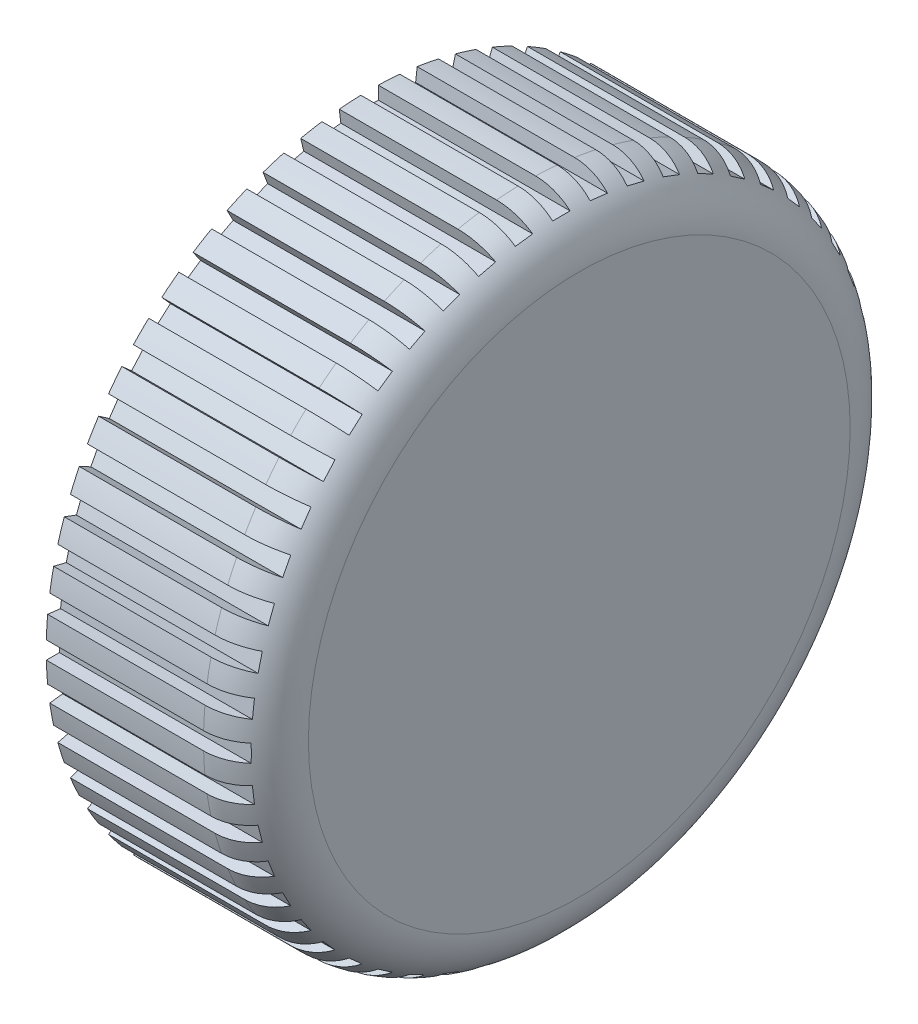
from build123d import *

# Parameters (mm, degrees)
SKETCH_2_W          = 2
SKETCH_2_H          = 3
SKETCH_2_W_2        = 3
SKETCH_2_H_2        = 2
CUT_EXTRUDE_2_DEPTH = 25


with BuildPart() as part:
    # Эскиз1 → Повернуть1 (revolve)
    with BuildSketch(Plane.XY):
        with BuildLine():
            Line((0, 37), (0, 30.3))
            Line((0, 30.3), (16, 30.3))
            Line((16, 30.3), (16, 0))
            Line((16, 0), (24, 0))
            Line((24, 0), (24, 31))
            ThreePointArc((24, 31), (22.242640687, 35.242640687), (18, 37))
            Line((18, 37), (0, 37))
        make_face()
    revolve(axis=Axis((0, 0, 0), (1, 0, 0)))

    # Эскиз2 → Вырез-Вытянуть2 (cut, through all)
    with BuildSketch(Plane.ZY):
        with Locations((0, 37)):
            Rectangle(SKETCH_2_W, SKETCH_2_H)
        Polygon((5.633371064, 38.098754973), (5.271761023, 35.12062835), (3.286343275, 35.361701711), (3.647953316, 38.339828333), align=None)
        Polygon((10.184594892, 37.141944307), (9.4666479, 34.229118854), (7.524764265, 34.707750183), (8.242711258, 37.620575635), align=None)
        Polygon((14.587304394, 35.643520456), (13.523489733, 32.838471728), (11.653457247, 33.547681502), (12.717271908, 36.35273023), align=None)
        Polygon((18.777298149, 33.625333816), (17.383128633, 30.968965739), (15.612216582, 31.898412083), (17.006386098, 34.55478016), align=None)
        Polygon((22.693476615, 31.11681409), (20.989282375, 28.647862492), (19.343314643, 29.783991986), (21.047508883, 32.252943584), align=None)
        Polygon((26.27873309, 28.154541146), (24.289365116, 25.909008902), (22.792343619, 27.235254218), (24.781711594, 29.480786463), align=None)
        Polygon((29.480786463, 24.781711594), (27.235254218, 22.792343619), (25.909008902, 24.289365116), (28.154541146, 26.27873309), align=None)
        Polygon((32.252943584, 21.047508883), (29.783991986, 19.343314643), (28.647862492, 20.989282375), (31.11681409, 22.693476615), align=None)
        Polygon((34.55478016, 17.006386098), (31.898412083, 15.612216582), (30.968965739, 17.383128633), (33.625333816, 18.777298149), align=None)
        Polygon((36.35273023, 12.717271908), (33.547681502, 11.653457247), (32.838471728, 13.523489733), (35.643520456, 14.587304394), align=None)
        Polygon((37.620575635, 8.242711258), (34.707750183, 7.524764265), (34.229118854, 9.4666479), (37.141944307, 10.184594892), align=None)
        Polygon((38.339828333, 3.647953316), (35.361701711, 3.286343275), (35.12062835, 5.271761023), (38.098754973, 5.633371064), align=None)
        with Locations((37, 0)):
            Rectangle(SKETCH_2_W_2, SKETCH_2_H_2)
        Polygon((38.098754973, -5.633371064), (35.12062835, -5.271761023), (35.361701711, -3.286343275), (38.339828333, -3.647953316), align=None)
        Polygon((37.141944307, -10.184594892), (34.229118854, -9.4666479), (34.707750183, -7.524764265), (37.620575635, -8.242711258), align=None)
        Polygon((35.643520456, -14.587304394), (32.838471728, -13.523489733), (33.547681502, -11.653457247), (36.35273023, -12.717271908), align=None)
        Polygon((33.625333816, -18.777298149), (30.968965739, -17.383128633), (31.898412083, -15.612216582), (34.55478016, -17.006386098), align=None)
        Polygon((31.11681409, -22.693476615), (28.647862492, -20.989282375), (29.783991986, -19.343314643), (32.252943584, -21.047508883), align=None)
        Polygon((28.154541146, -26.27873309), (25.909008902, -24.289365116), (27.235254218, -22.792343619), (29.480786463, -24.781711594), align=None)
        Polygon((24.781711594, -29.480786463), (22.792343619, -27.235254218), (24.289365116, -25.909008902), (26.27873309, -28.154541146), align=None)
        Polygon((21.047508883, -32.252943584), (19.343314643, -29.783991986), (20.989282375, -28.647862492), (22.693476615, -31.11681409), align=None)
        Polygon((17.006386098, -34.55478016), (15.612216582, -31.898412083), (17.383128633, -30.968965739), (18.777298149, -33.625333816), align=None)
        Polygon((12.717271908, -36.35273023), (11.653457247, -33.547681502), (13.523489733, -32.838471728), (14.587304394, -35.643520456), align=None)
        Polygon((8.242711258, -37.620575635), (7.524764265, -34.707750183), (9.4666479, -34.229118854), (10.184594892, -37.141944307), align=None)
        Polygon((3.647953316, -38.339828333), (3.286343275, -35.361701711), (5.271761023, -35.12062835), (5.633371064, -38.098754973), align=None)
        with Locations((0, -37)):
            Rectangle(SKETCH_2_W, SKETCH_2_H)
        Polygon((-5.633371064, -38.098754973), (-5.271761023, -35.12062835), (-3.286343275, -35.361701711), (-3.647953316, -38.339828333), align=None)
        Polygon((-10.184594892, -37.141944307), (-9.4666479, -34.229118854), (-7.524764265, -34.707750183), (-8.242711258, -37.620575635), align=None)
        Polygon((-14.587304394, -35.643520456), (-13.523489733, -32.838471728), (-11.653457247, -33.547681502), (-12.717271908, -36.35273023), align=None)
        Polygon((-18.777298149, -33.625333816), (-17.383128633, -30.968965739), (-15.612216582, -31.898412083), (-17.006386098, -34.55478016), align=None)
        Polygon((-22.693476615, -31.11681409), (-20.989282375, -28.647862492), (-19.343314643, -29.783991986), (-21.047508883, -32.252943584), align=None)
        Polygon((-26.27873309, -28.154541146), (-24.289365116, -25.909008902), (-22.792343619, -27.235254218), (-24.781711594, -29.480786463), align=None)
        Polygon((-29.480786463, -24.781711594), (-27.235254218, -22.792343619), (-25.909008902, -24.289365116), (-28.154541146, -26.27873309), align=None)
        Polygon((-32.252943584, -21.047508883), (-29.783991986, -19.343314643), (-28.647862492, -20.989282375), (-31.11681409, -22.693476615), align=None)
        Polygon((-34.55478016, -17.006386098), (-31.898412083, -15.612216582), (-30.968965739, -17.383128633), (-33.625333816, -18.777298149), align=None)
        Polygon((-36.35273023, -12.717271908), (-33.547681502, -11.653457247), (-32.838471728, -13.523489733), (-35.643520456, -14.587304394), align=None)
        Polygon((-37.620575635, -8.242711258), (-34.707750183, -7.524764265), (-34.229118854, -9.4666479), (-37.141944307, -10.184594892), align=None)
        Polygon((-38.339828333, -3.647953316), (-35.361701711, -3.286343275), (-35.12062835, -5.271761023), (-38.098754973, -5.633371064), align=None)
        with Locations((-37, 0)):
            Rectangle(SKETCH_2_W_2, SKETCH_2_H_2)
        Polygon((-38.098754973, 5.633371064), (-35.12062835, 5.271761023), (-35.361701711, 3.286343275), (-38.339828333, 3.647953316), align=None)
        Polygon((-37.141944307, 10.184594892), (-34.229118854, 9.4666479), (-34.707750183, 7.524764265), (-37.620575635, 8.242711258), align=None)
        Polygon((-35.643520456, 14.587304394), (-32.838471728, 13.523489733), (-33.547681502, 11.653457247), (-36.35273023, 12.717271908), align=None)
        Polygon((-33.625333816, 18.777298149), (-30.968965739, 17.383128633), (-31.898412083, 15.612216582), (-34.55478016, 17.006386098), align=None)
        Polygon((-31.11681409, 22.693476615), (-28.647862492, 20.989282375), (-29.783991986, 19.343314643), (-32.252943584, 21.047508883), align=None)
        Polygon((-28.154541146, 26.27873309), (-25.909008902, 24.289365116), (-27.235254218, 22.792343619), (-29.480786463, 24.781711594), align=None)
        Polygon((-24.781711594, 29.480786463), (-22.792343619, 27.235254218), (-24.289365116, 25.909008902), (-26.27873309, 28.154541146), align=None)
        Polygon((-21.047508883, 32.252943584), (-19.343314643, 29.783991986), (-20.989282375, 28.647862492), (-22.693476615, 31.11681409), align=None)
        Polygon((-17.006386098, 34.55478016), (-15.612216582, 31.898412083), (-17.383128633, 30.968965739), (-18.777298149, 33.625333816), align=None)
        Polygon((-12.717271908, 36.35273023), (-11.653457247, 33.547681502), (-13.523489733, 32.838471728), (-14.587304394, 35.643520456), align=None)
        Polygon((-8.242711258, 37.620575635), (-7.524764265, 34.707750183), (-9.4666479, 34.229118854), (-10.184594892, 37.141944307), align=None)
        Polygon((-3.647953316, 38.339828333), (-3.286343275, 35.361701711), (-5.271761023, 35.12062835), (-5.633371064, 38.098754973), align=None)
    extrude(amount=-CUT_EXTRUDE_2_DEPTH, mode=Mode.SUBTRACT)


solid = part.part
